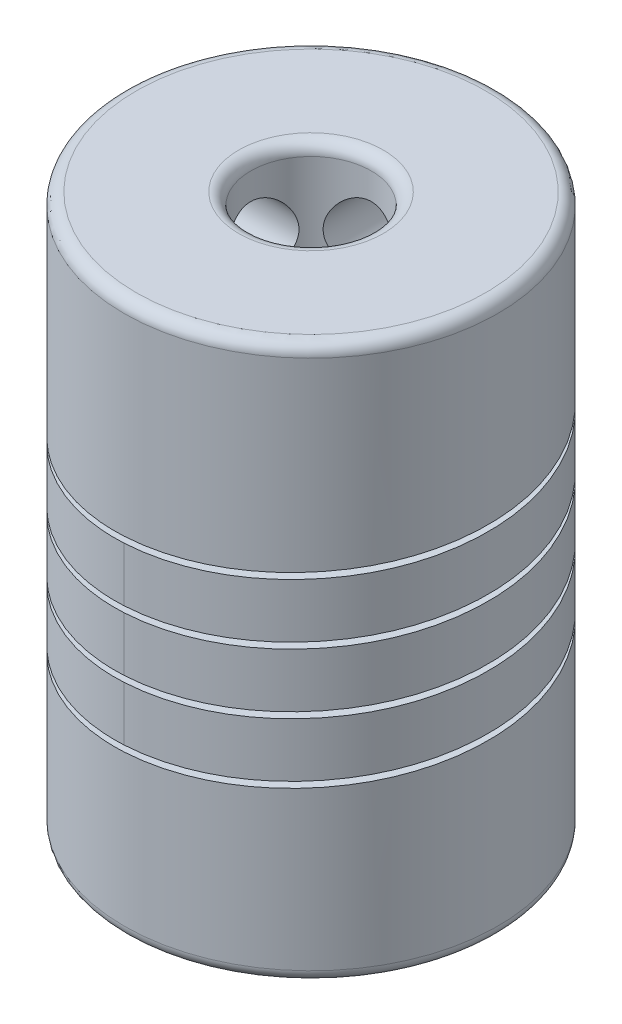
from build123d import *

# Parameters (mm, degrees)
SKETCH1_R                = 7.75
BOSS_EXTRUDE1_DEPTH      = 11.5
SKETCH2_R                = 2.5
CUT_EXTRUDE1_DEPTH       = 6
SKETCH12_R               = 4
CUT_EXTRUDE3_DEPTH       = 17
SKETCH3_R                = 1.5
CUT_EXTRUDE2_DEPTH       = 5.75
FILLET1_R                = 0.5
FILLET3_R                = 0.25
CUT_SWEEP2_PITCH         = 2.5
CUT_SWEEP2_HEIGHT        = 10
CUT_SWEEP2_RADIUS        = 9.521109848
CUT_SWEEP2_START_ANGLE   = -90
SKETCH8_W                = 11.5
SKETCH8_H                = 0.25
CIRPATTERN1_COUNT        = 2
CIRPATTERN1_ANGLE        = 90
FILLET3_OF_CIRPATTERN1_R = 0.25
FILLET4_R                = 0.5


with BuildPart() as part:
    # Sketch1 → Boss-Extrude1 (new body, symmetric)
    with BuildSketch(Plane(origin=(0, 0, 0), x_dir=(1, 0, 0), z_dir=(0, 1, 0))):
        Circle(SKETCH1_R)
    extrude(amount=BOSS_EXTRUDE1_DEPTH, both=True)

    # Sketch2 → Cut-Extrude1 (cut)
    with BuildSketch(Plane(origin=(0, 11.5, 0), x_dir=(1, 0, 0), z_dir=(0, 1, 0))):
        Circle(SKETCH2_R)
    extrude(amount=-CUT_EXTRUDE1_DEPTH, mode=Mode.SUBTRACT)

    # Sketch12 → Cut-Extrude3 (cut)
    with BuildSketch(Plane.XZ.offset(11.5)):
        Circle(SKETCH12_R)
    extrude(amount=-CUT_EXTRUDE3_DEPTH, mode=Mode.SUBTRACT)

    # Sketch3 → Cut-Extrude2 (cut)
    with BuildSketch(Plane.ZY.offset(7.75)):
        with Locations((0, 8.4)):
            Circle(SKETCH3_R)
        with Locations((0, -8.4)):
            Circle(SKETCH3_R)
    cut_extrude2 = extrude(amount=-CUT_EXTRUDE2_DEPTH, mode=Mode.SUBTRACT)

    # Fillet1
    fillet1_edges = [part.edges().sort_by_distance(p)[0] for p in [
        (-7.75, -11.5, 0),
        (-7.75, 11.5, 0),
    ]]
    fillet(fillet1_edges, radius=FILLET1_R)

    # Fillet3
    fillet3_edges = [part.edges().sort_by_distance(p)[0] for p in [
        (-7.603453163, 8.4, -1.5),
        (-7.603453163, -8.4, -1.5),
    ]]
    fillet(fillet3_edges, radius=FILLET3_R)

    # Cut-Sweep2: sweep along a helix
    with BuildLine() as cut_sweep2_path:
        add(Helix(CUT_SWEEP2_PITCH, CUT_SWEEP2_HEIGHT, CUT_SWEEP2_RADIUS, center=(0, -5, 0), direction=(0, 1, 0), mode=Mode.PRIVATE).rotate(Axis((0, -5, 0), (0, 1, 0)), CUT_SWEEP2_START_ANGLE))
    # Sketch8 → Cut-Sweep2 (sweep, cut)
    with BuildSketch(Plane.XY):
        with Locations((-7.75, -2.746584583)):
            Rectangle(SKETCH8_W, SKETCH8_H)
    sweep(path=cut_sweep2_path.line, is_frenet=True, mode=Mode.SUBTRACT)

    # CirPattern1: Cut-Extrude2 ×2 about axis
    cirpattern1_axis = Axis((0, 11, 0), (0, -1, 0))
    for i in range(1, CIRPATTERN1_COUNT):
        add(cut_extrude2.rotate(cirpattern1_axis, i * CIRPATTERN1_ANGLE / (CIRPATTERN1_COUNT - 1)), mode=Mode.SUBTRACT)

    # Fillet3 of CirPattern1
    fillet3_of_cirpattern1_edges = [part.edges().sort_by_distance(p)[0] for p in [
        (1.5, 8.4, -7.603453163),
        (1.5, -8.4, -7.603453163),
    ]]
    fillet(fillet3_of_cirpattern1_edges, radius=FILLET3_OF_CIRPATTERN1_R)

    # Fillet4
    fillet4_edges = [part.edges().sort_by_distance(p)[0] for p in [
        (-4, -11.5, 0),
        (-2.5, 11.5, 0),
    ]]
    fillet(fillet4_edges, radius=FILLET4_R)


solid = part.part
